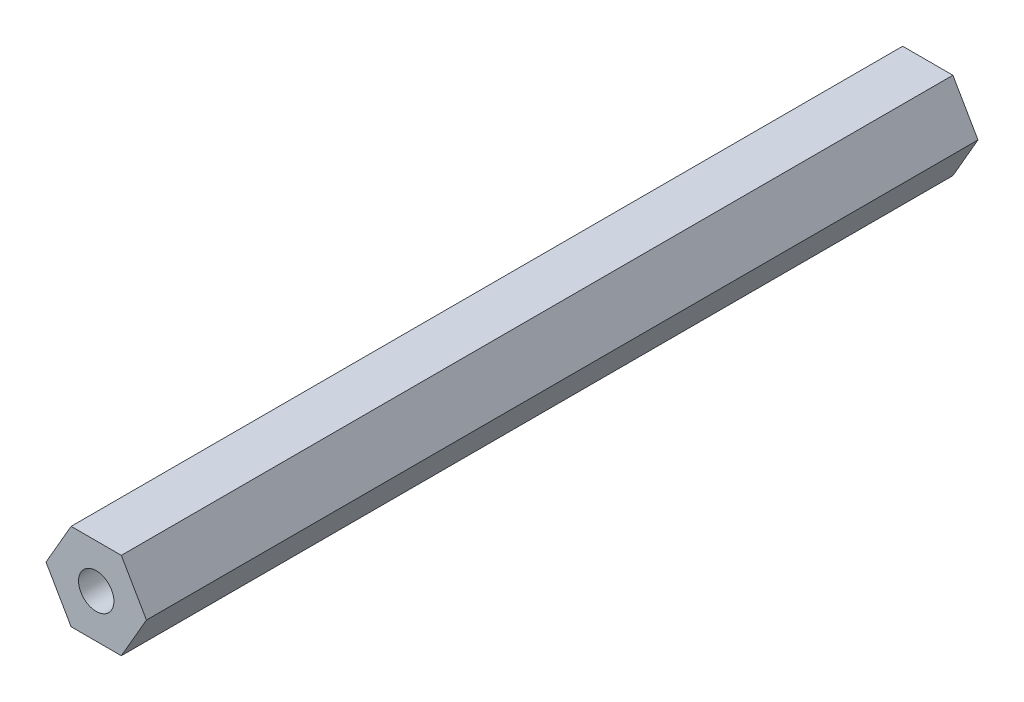
from build123d import *

# Parameters (mm, degrees)
BOSS_EXTRUDE1_DEPTH = 121.412
SKETCH2_R           = 2.5796875
CUT_EXTRUDE1_DEPTH  = 12.7


with BuildPart() as part:
    # Sketch1 → Boss-Extrude1 (new body)
    with BuildSketch(Plane.XY):
        Polygon((7.332348419, 0), (3.666174209, 6.35), (-3.666174209, 6.35), (-7.332348419, 0), (-3.666174209, -6.35), (3.666174209, -6.35), align=None)
    extrude(amount=BOSS_EXTRUDE1_DEPTH)

    # Sketch2 → Cut-Extrude1 (cut)
    with BuildSketch(Plane.XY.offset(121.412)):
        Circle(SKETCH2_R)
    cut_extrude1 = extrude(amount=-CUT_EXTRUDE1_DEPTH, mode=Mode.SUBTRACT)

    # Mirror1: Cut-Extrude1 across plane
    add(cut_extrude1.mirror(Plane.XY.offset(60.706)), mode=Mode.SUBTRACT)


solid = part.part
